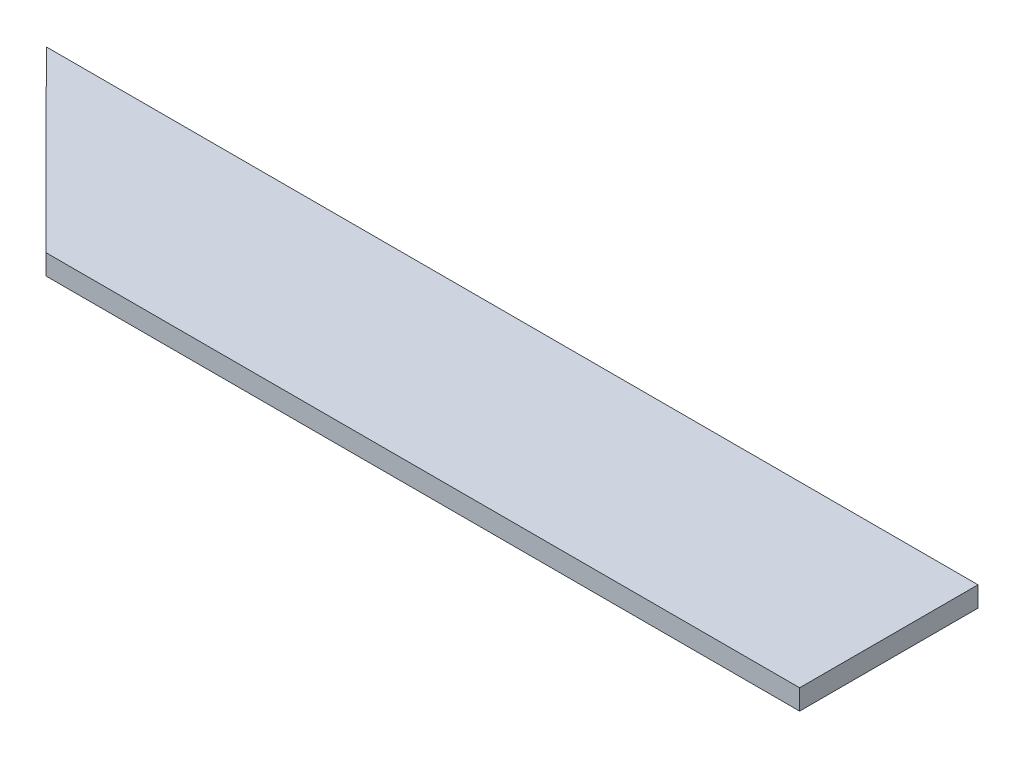
from build123d import *

# Parameters (mm, degrees)
BOSS_EXTRUDE1_DEPTH = 3


with BuildPart() as part:
    # Sketch1 → Boss-Extrude1 (new body)
    with BuildSketch(Plane(origin=(0, 0, 0), x_dir=(1, 0, 0), z_dir=(0, 1, 0))):
        Polygon((-99.155199252, 31.992171884), (-72.779752276, 5.570852808), (38.844800748, 5.570852808), (38.844800748, 31.992171884), align=None)
    extrude(amount=BOSS_EXTRUDE1_DEPTH)


solid = part.part
